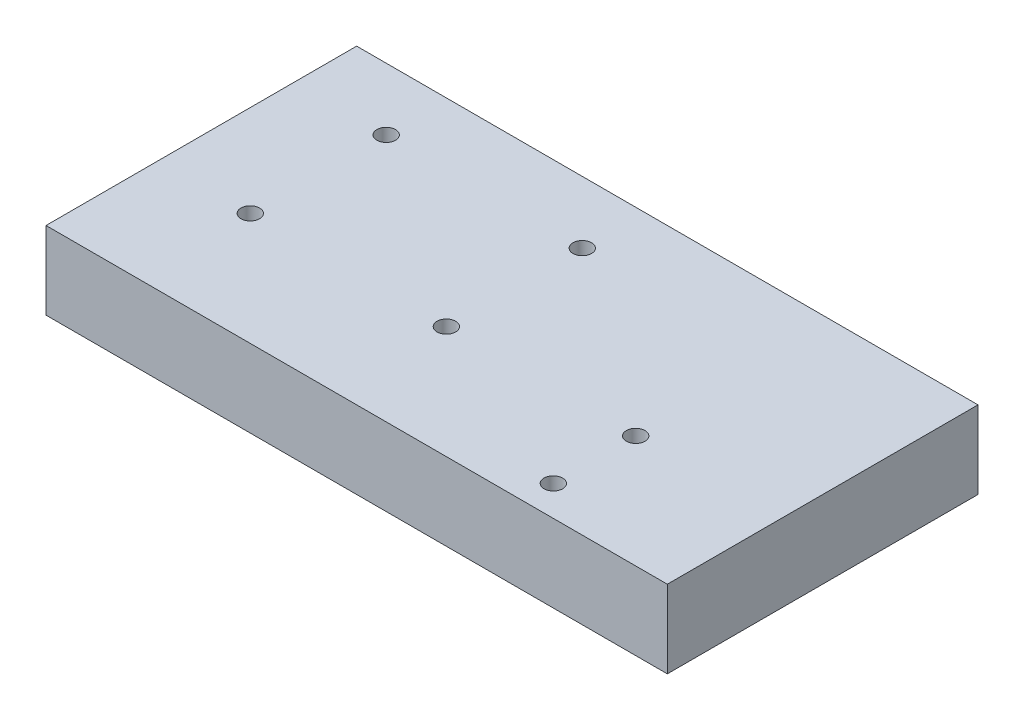
from build123d import *

# Parameters (mm, degrees)
SKETCH1_W                = 80
SKETCH1_H                = 40
BOSS_EXTRUDE1_DEPTH      = 10
M2_CLEARANCE_HOLE1_D     = 2.4
M2_CLEARANCE_HOLE1_DEPTH = 6
M2_CLEARANCE_HOLE1_TIP   = 0.721032743


with BuildPart() as part:
    # Sketch1 → Boss-Extrude1 (new body)
    with BuildSketch(Plane(origin=(0, 0, 0), x_dir=(1, 0, 0), z_dir=(0, 1, 0))):
        with Locations((40, 20)):
            Rectangle(SKETCH1_W, SKETCH1_H)
    extrude(amount=-BOSS_EXTRUDE1_DEPTH)

    # M2 Clearance Hole1
    with Locations(Plane(origin=(0, 0, 0), x_dir=(1, 0, 0), z_dir=(0, 1, 0))):
        with Locations((11.8, 32), (37.05, 32), (37.05, 14.5), (11.8, 14.5), (61.425, 14.5), (61.425, 3.9)):
            Hole(M2_CLEARANCE_HOLE1_D / 2, depth=M2_CLEARANCE_HOLE1_DEPTH)
            with Locations((0, 0, -(M2_CLEARANCE_HOLE1_DEPTH + M2_CLEARANCE_HOLE1_TIP / 2))):  # 118° drill point
                Cone(0, M2_CLEARANCE_HOLE1_D / 2, M2_CLEARANCE_HOLE1_TIP, mode=Mode.SUBTRACT)


solid = part.part
